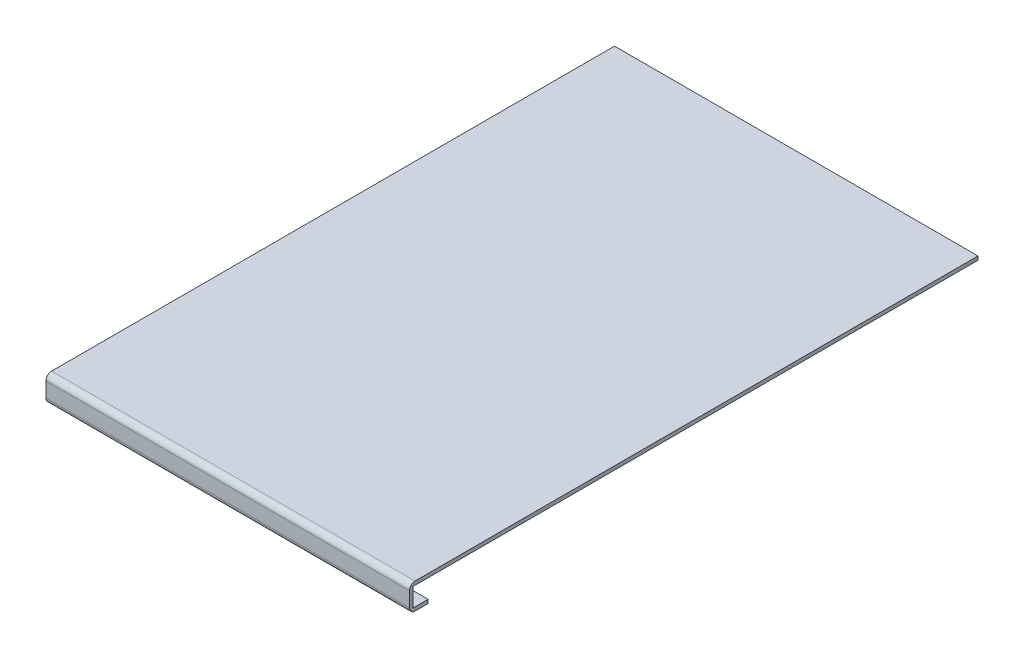
from build123d import *

# Parameters (mm, degrees)
RESSALTO_EXTRUS_O1_DEPTH = 195
RESSALTO_EXTRUS_O2_DEPTH = 2
FILETE1_R                = 3


with BuildPart() as part:
    # Esboço1 → Ressalto-extrusão1 (new body)
    with BuildSketch(Plane(origin=(0, 0, 0), x_dir=(0, 0, -1), z_dir=(1, 0, 0))):
        Polygon((0, 0), (-150, 0), (-150, -14), (-140, -14), (-140, -12), (-148, -12), (-148, -2), (0, -2), (155, -2), (155, 0), align=None)
    extrude(amount=RESSALTO_EXTRUS_O1_DEPTH)

    # Filete1
    filete1_edges = [part.edges().sort_by_distance(p)[0] for p in [
        (97.5, -14, 150),
        (97.5, 0, 150),
    ]]
    fillet(filete1_edges, radius=FILETE1_R)


with BuildPart() as body_2:
    # Esboço2 → Ressalto-extrusão2 (new body)
    with BuildSketch(Plane(origin=(0, 0, -155), x_dir=(-1, 0, 0), z_dir=(0, 0, -1))):
        Polygon((-37.5, 0), (-157.5, 0), (-147.5, -12), (-47.5, -12), align=None)
    extrude(amount=-RESSALTO_EXTRUS_O2_DEPTH)


solid = Compound([part.part, body_2.part])
